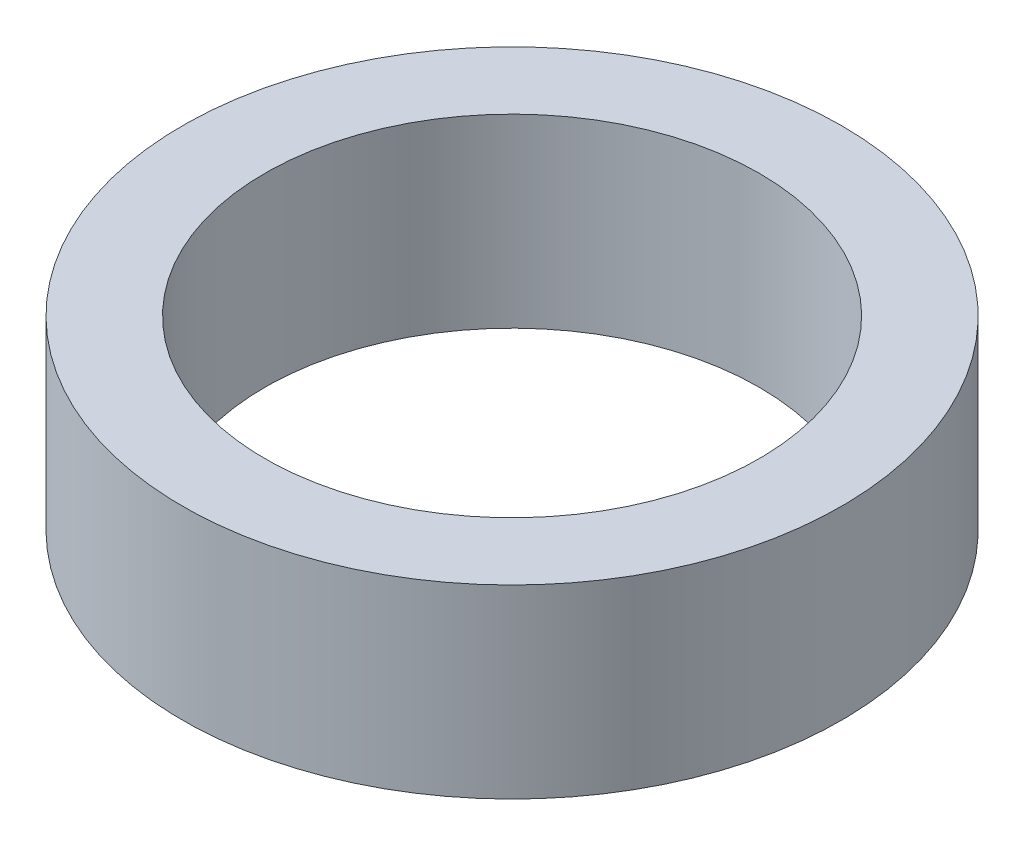
from build123d import *

# Parameters (mm, degrees)
SKETCH1_W = 0.2
SKETCH1_H = 0.45


with BuildPart() as part:
    # Sketch1 → Revolve1 (revolve)
    with BuildSketch(Plane.XY):
        with Locations((0.7, 0.225)):
            Rectangle(SKETCH1_W, SKETCH1_H)
    revolve(axis=Axis((0, 0.45, 0), (0, -1, 0)))


solid = part.part
